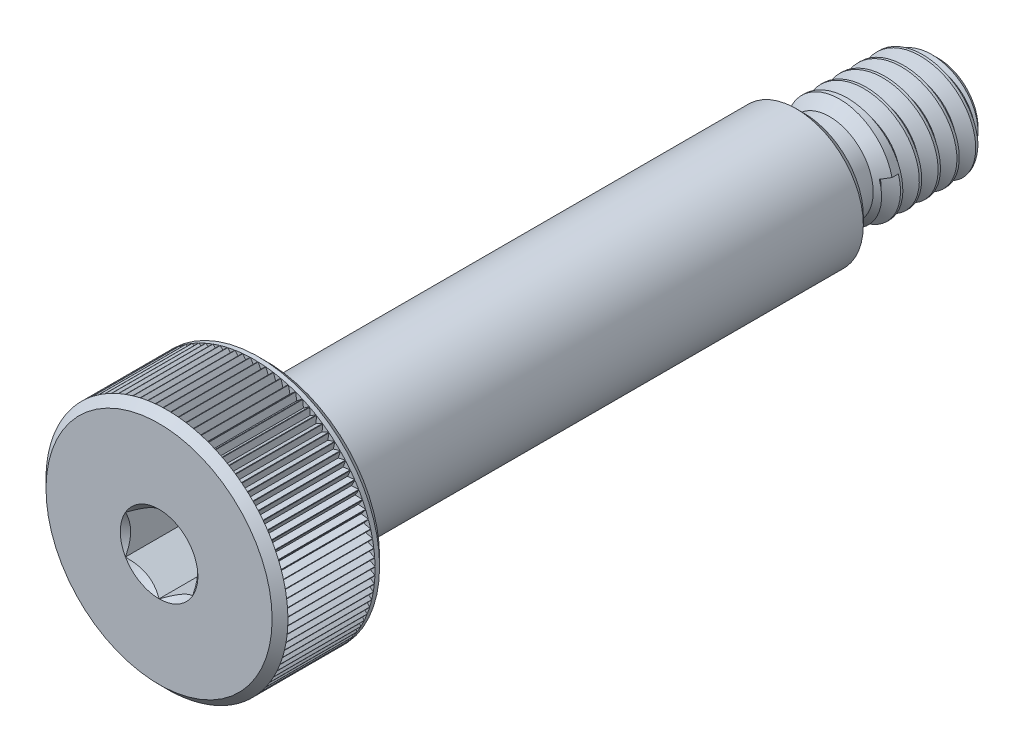
from build123d import *

# Parameters (mm, degrees)
CUT_EXTRUDE1_START     = 14.5
CUT_EXTRUDE1_DEPTH     = 2
CHAMFER1_SIZE          = 0.2925
CUT_SWEEP1_PITCH       = 0.6999999999999992
CUT_SWEEP1_HEIGHT      = 4.05
CUT_SWEEP1_RADIUS      = 2.000000000000004
CUT_SWEEP1_START_ANGLE = 89.99999999999983
CUT_EXTRUDE3_START     = 14.2075
CUT_EXTRUDE3_DEPTH     = 3.244249999999999
CIRPATTERN1_COUNT      = 99


with BuildPart() as part:
    # Sketch3 → Revolve1 (revolve)
    with BuildSketch(Plane(origin=(0, 0, 0), x_dir=(0, 0, -1), z_dir=(1, 0, 0)), mode=Mode.PRIVATE) as revolve1_sk:
        with BuildLine():
            Line((-14.5, 0), (-14.5, 4.2075))
            Line((-14.5, 4.2075), (-14.207500000000003, 4.499999999999999))
            Line((-14.207500000000003, 4.499999999999999), (-10.7925, 4.499999999999999))
            Line((-10.7925, 4.499999999999999), (-10.5, 4.207500000000003))
            Line((-10.5, 4.207500000000003), (-10.5, 2.296999999999999))
            Line((-10.5, 2.296999999999999), (-9.992, 2.296999999999999))
            Line((-9.992, 2.296999999999999), (-9.789000000000003, 2.4999999999999982))
            Line((-9.789000000000003, 2.4999999999999982), (9.5, 2.4999999999999996))
            Line((9.5, 2.4999999999999996), (9.5, 1.8125000000000007))
            ThreePointArc((9.5, 1.8125000000000007), (9.554917478527523, 1.6799174785275224), (9.687500000000002, 1.6250000000000004))
            Line((9.687500000000002, 1.6250000000000004), (10.45, 1.6250000000000002))
            Line((10.45, 1.6250000000000002), (10.824999999999998, 2.000000000000003))
            Line((10.824999999999998, 2.000000000000003), (13.975000000000001, 2.0000000000000036))
            Line((13.975000000000001, 2.0000000000000036), (14.5, 1.4750000000000087))
            Line((14.5, 1.4750000000000087), (14.499999999999998, 0))
            Line((14.499999999999998, 0), (-14.5, 0))
        make_face()
    revolve(revolve1_sk.sketch.rotate(Axis((0, 0, 14.499999999999998), (0, 0, -1)), 90), axis=Axis((0, 0, 14.499999999999998), (0, 0, -1)))

    # Sketch4 → Cut-Extrude1 (cut)
    with BuildSketch(Plane.XY.offset(CUT_EXTRUDE1_START)):
        Polygon((-8.5e-16, 1.4433756729740645), (-1.2500000000000002, 0.7216878364870319), (-1.2500000000000002, -0.721687836487033), (1.04e-15, -1.443375672974065), (1.2500000000000009, -0.7216878364870319), (1.2500000000000004, 0.7216878364870327), align=None)
    extrude(amount=-CUT_EXTRUDE1_DEPTH, mode=Mode.SUBTRACT)

    # Cut-Extrude2 cone 1 section (through the dimple's axis) → Cut-Extrude2 (revolve, cut)
    with BuildSketch(Plane(origin=(0, 0, 14.5), x_dir=(0, -1, 0), z_dir=(1, 0, 0))):
        Polygon((0, 0), (1.443375673, 0), (0, 1.443375673), align=None)
    revolve(axis=Axis((0, 0, 14.5), (0, 0, -1)), mode=Mode.SUBTRACT)

    # Chamfer1
    chamfer1_edges = [part.edges().sort_by_distance(p)[0] for p in [
        (-2.4999999999999996, -5.8e-16, -9.500000000000002),
    ]]
    chamfer(chamfer1_edges, length=CHAMFER1_SIZE)

    # Cut-Sweep1: sweep along a helix
    with BuildLine() as cut_sweep1_path:
        add(Helix(CUT_SWEEP1_PITCH, CUT_SWEEP1_HEIGHT, CUT_SWEEP1_RADIUS, center=(0, 0, -14.499999999999998), direction=(0, 0, 1), mode=Mode.PRIVATE).rotate(Axis((0, 0, -14.499999999999998), (0, 0, 1)), CUT_SWEEP1_START_ANGLE))
    # Sketch7 → Cut-Sweep1 (sweep, cut)
    with BuildSketch(Plane(origin=(0, 0, 0), x_dir=(0, 0, -1), z_dir=(1, 0, 0))):
        Polygon((14.478125000000002, 2.0378886114155725), (14.762500000000001, 1.5453366630131748), (14.850000000000001, 1.5453366630131748), (15.134375000000002, 2.0378886114155725), align=None)
    sweep(path=cut_sweep1_path.line, is_frenet=True, mode=Mode.SUBTRACT)

    # Sketch8 → Cut-Extrude3 (cut)
    with BuildSketch(Plane.XY.offset(CUT_EXTRUDE3_START)):
        Polygon((-0.13509996299037247, 4.499999999999999), (0.13509996299037247, 4.499999999999999), (0, 4.265999999999999), align=None)
    cut_extrude3 = extrude(amount=-CUT_EXTRUDE3_DEPTH, mode=Mode.SUBTRACT)

    # CirPattern1: Cut-Extrude3 ×99 about axis
    cirpattern1_axis = Axis((-1.6e-16, 9e-17, 0), (0, 0, 1))
    for i in range(1, CIRPATTERN1_COUNT):
        add(cut_extrude3.rotate(cirpattern1_axis, i * 360 / CIRPATTERN1_COUNT), mode=Mode.SUBTRACT)


solid = part.part
